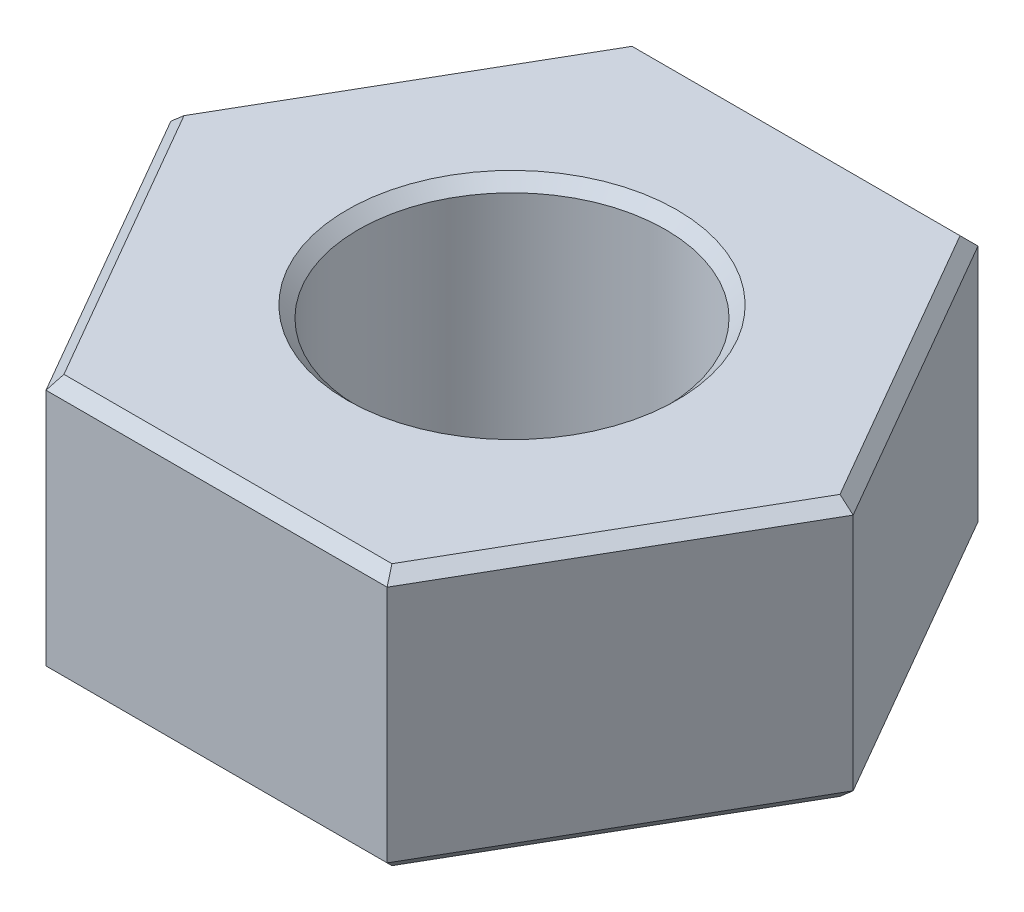
from build123d import *

# Parameters (mm, degrees)
SKETCH_1_R      = 1.35
EXTRUDE_1_DEPTH = 2.3
CHAMFER_1_SIZE  = 0.1


with BuildPart() as part:
    # Эскиз1 → Бобышка-Вытянуть1 (new body)
    with BuildSketch(Plane(origin=(0, 0, 0), x_dir=(1, 0, 0), z_dir=(0, 1, 0))):
        Polygon((3, 0), (1.5, 2.598076211), (-1.5, 2.598076211), (-3, 0), (-1.5, -2.598076211), (1.5, -2.598076211), align=None)
        Circle(SKETCH_1_R, mode=Mode.SUBTRACT)
    extrude(amount=EXTRUDE_1_DEPTH)

    # Фаска1
    chamfer_1_edges = [part.edges().sort_by_distance(p)[0] for p in [
        (0, 2.3, -2.598076211),
        (-2.25, 2.3, -1.299038106),
        (-2.25, 2.3, 1.299038106),
        (-1.35, 0, 0),
        (-1.35, 2.3, 0),
        (0, 2.3, 2.598076211),
        (2.25, 2.3, 1.299038106),
        (0, 0, 2.598076211),
        (-2.25, 0, 1.299038106),
        (-2.25, 0, -1.299038106),
        (2.25, 2.3, -1.299038106),
        (0, 0, -2.598076211),
        (2.25, 0, -1.299038106),
        (2.25, 0, 1.299038106),
    ]]
    chamfer(chamfer_1_edges, length=CHAMFER_1_SIZE)


solid = part.part
